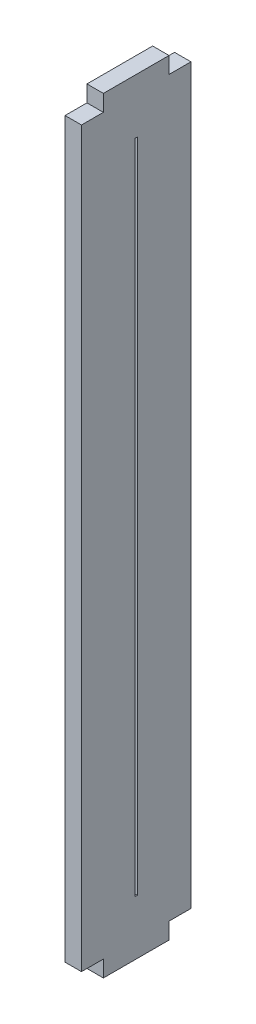
from build123d import *

# Parameters (mm, degrees)
SKETCH1_W           = 10
SKETCH1_H           = 70
BOSS_EXTRUDE1_DEPTH = 1.5
SKETCH2_W           = 2
SKETCH2_H           = 1.5
CUT_EXTRUDE1_DEPTH  = 10
SKETCH3_W           = 0.2
SKETCH3_H           = 60
CUT_EXTRUDE2_DEPTH  = 10


with BuildPart() as part:
    # Sketch1 → Boss-Extrude1 (new body)
    with BuildSketch(Plane(origin=(0, 0, 0), x_dir=(0, 0, -1), z_dir=(1, 0, 0))):
        with Locations((-5, 4.155844156)):
            Rectangle(SKETCH1_W, SKETCH1_H)
    extrude(amount=BOSS_EXTRUDE1_DEPTH)

    # Sketch2 → Cut-Extrude1 (cut)
    with BuildSketch(Plane(origin=(1.5, 0, 0), x_dir=(0, 0, -1), z_dir=(1, 0, 0))):
        with Locations((-9, 38.405844156)):
            Rectangle(SKETCH2_W, SKETCH2_H)
        with Locations((-1, 38.405844156)):
            Rectangle(SKETCH2_W, SKETCH2_H)
        with Locations((-1, -30.094155844)):
            Rectangle(SKETCH2_W, SKETCH2_H)
        with Locations((-9, -30.094155844)):
            Rectangle(SKETCH2_W, SKETCH2_H)
    extrude(amount=-CUT_EXTRUDE1_DEPTH, mode=Mode.SUBTRACT)

    # Sketch3 → Cut-Extrude2 (cut)
    with BuildSketch(Plane(origin=(1.5, 0, 0), x_dir=(0, 0, -1), z_dir=(1, 0, 0))):
        with Locations((-5, 4.155844156)):
            Rectangle(SKETCH3_W, SKETCH3_H)
    extrude(amount=-CUT_EXTRUDE2_DEPTH, mode=Mode.SUBTRACT)


solid = part.part
